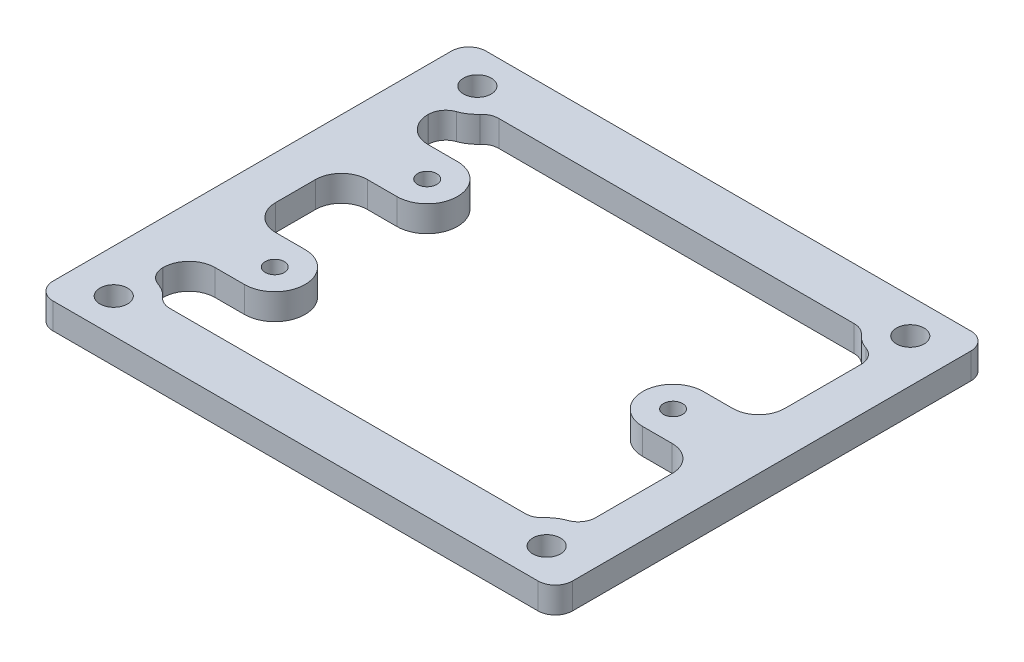
from build123d import *

# Parameters (mm, degrees)
SKETCH_1_W      = 60
SKETCH_1_H      = 50
SKETCH_1_R      = 1.6
SKETCH_1_R_2    = 1.1
EXTRUDE_1_DEPTH = 3
FILLET_1_R      = 2
FILLET_2_R      = 2
FILLET_3_R      = 3


with BuildPart() as part:
    # 草图1 → 凸台-拉伸1 (new body)
    with BuildSketch(Plane(origin=(0, 0, 0), x_dir=(1, 0, 0), z_dir=(0, 1, 0))):
        Rectangle(SKETCH_1_W, SKETCH_1_H)
        with Locations((-25, 21)):
            Circle(SKETCH_1_R, mode=Mode.SUBTRACT)
        with Locations((25, 21)):
            Circle(SKETCH_1_R, mode=Mode.SUBTRACT)
        with Locations((25, -21)):
            Circle(SKETCH_1_R, mode=Mode.SUBTRACT)
        with Locations((-25, -21)):
            Circle(SKETCH_1_R, mode=Mode.SUBTRACT)
        with Locations((18.6, 0)):
            Circle(SKETCH_1_R_2, mode=Mode.SUBTRACT)
        with Locations((-18.6, 8.8)):
            Circle(SKETCH_1_R_2, mode=Mode.SUBTRACT)
        with Locations((-18.6, -8.8)):
            Circle(SKETCH_1_R_2, mode=Mode.SUBTRACT)
        with BuildLine():
            Line((-25, -5.3), (-25, 5.3))
            Line((-25, 5.3), (-18.6, 5.3))
            ThreePointArc((-18.6, 5.3), (-15.1, 8.8), (-18.6, 12.3))
            Line((-18.6, 12.3), (-25, 12.3))
            Line((-25, 12.3), (-25, 17))
            ThreePointArc((-25, 17), (-23, 17.535898385), (-21.535898385, 19))
            Line((-21.535898385, 19), (21.535898385, 19))
            ThreePointArc((21.535898385, 19), (23, 17.535898385), (25, 17))
            Line((25, 17), (25, 3.5))
            Line((25, 3.5), (18.6, 3.5))
            ThreePointArc((18.6, 3.5), (15.1, 0), (18.6, -3.5))
            Line((18.6, -3.5), (25, -3.5))
            Line((25, -3.5), (25, -17))
            ThreePointArc((25, -17), (23, -17.535898385), (21.535898385, -19))
            Line((21.535898385, -19), (-21.535898385, -19))
            ThreePointArc((-21.535898385, -19), (-23, -17.535898385), (-25, -17))
            Line((-25, -17), (-25, -12.3))
            Line((-25, -12.3), (-18.6, -12.3))
            ThreePointArc((-18.6, -12.3), (-15.1, -8.8), (-18.6, -5.3))
            Line((-18.6, -5.3), (-25, -5.3))
        make_face(mode=Mode.SUBTRACT)
    extrude(amount=EXTRUDE_1_DEPTH)

    # 圆角1
    fillet_1_edges = [part.edges().sort_by_distance(p)[0] for p in [
        (30, 1.5, 25),
        (-30, 1.5, 25),
        (-30, 1.5, -25),
        (30, 1.5, -25),
    ]]
    fillet(fillet_1_edges, radius=FILLET_1_R)

    # 圆角2
    fillet_2_edges = [part.edges().sort_by_distance(p)[0] for p in [
        (-25, 1.5, 17),
        (-21.535898385, 1.5, 19),
        (21.535898385, 1.5, 19),
        (25, 1.5, 17),
        (25, 1.5, -17),
        (21.535898385, 1.5, -19),
        (-21.535898385, 1.5, -19),
        (-25, 1.5, -17),
    ]]
    fillet(fillet_2_edges, radius=FILLET_2_R)

    # 圆角3
    fillet_3_edges = [part.edges().sort_by_distance(p)[0] for p in [
        (-25, 1.5, -5.3),
        (-25, 1.5, 5.3),
        (-25, 1.5, 12.3),
        (25, 1.5, 3.5),
        (25, 1.5, -3.5),
        (-25, 1.5, -12.3),
    ]]
    fillet(fillet_3_edges, radius=FILLET_3_R)


solid = part.part
